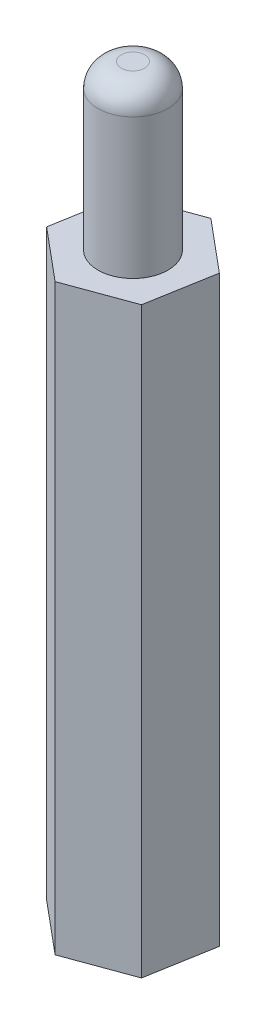
from build123d import *

# Parameters (mm, degrees)
BOSS_EXTRUDE1_DEPTH = 25
SKETCH2_R           = 1.5
BOSS_EXTRUDE2_DEPTH = 7
SKETCH3_R           = 1.5
CUT_EXTRUDE1_DEPTH  = 7
FILLET1_R           = 1


with BuildPart() as part:
    # Sketch1 → Boss-Extrude1 (new body)
    with BuildSketch(Plane(origin=(0, 0, 0), x_dir=(1, 0, 0), z_dir=(0, 1, 0))):
        Polygon((2.214824591, -1.851454932), (2.7108193, 0.992366895), (0.495994709, 2.843821827), (-2.214824591, 1.851454932), (-2.7108193, -0.992366895), (-0.495994709, -2.843821827), align=None)
    extrude(amount=BOSS_EXTRUDE1_DEPTH)

    # Sketch2 → Boss-Extrude2 (add)
    with BuildSketch(Plane(origin=(0, 25, 0), x_dir=(1, 0, 0), z_dir=(0, 1, 0))):
        Circle(SKETCH2_R)
    extrude(amount=BOSS_EXTRUDE2_DEPTH)

    # Sketch3 → Cut-Extrude1 (cut)
    with BuildSketch(Plane.XZ):
        Circle(SKETCH3_R)
    extrude(amount=-CUT_EXTRUDE1_DEPTH, mode=Mode.SUBTRACT)

    # Fillet1
    fillet1_edges = [part.edges().sort_by_distance(p)[0] for p in [
        (-1.5, 32, 0),
    ]]
    fillet(fillet1_edges, radius=FILLET1_R)


solid = part.part
